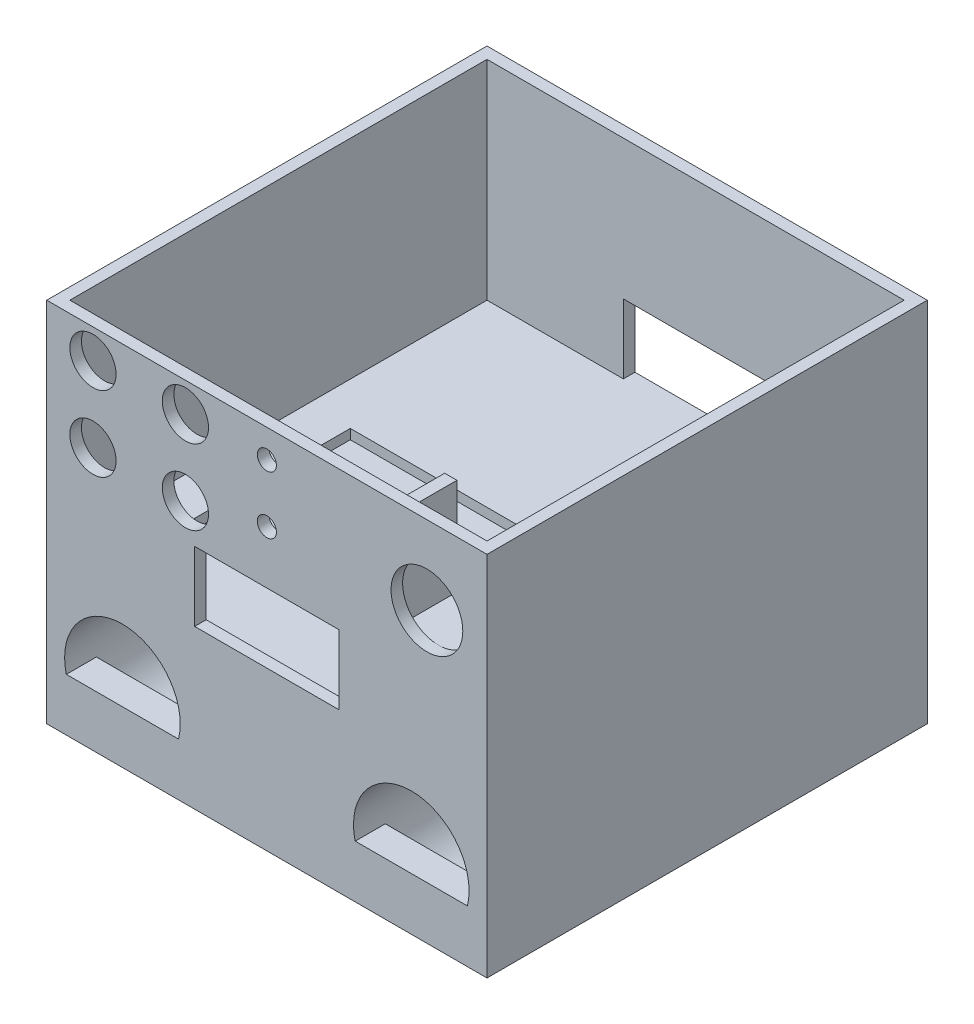
from build123d import *

# Parameters (mm, degrees)
SKETCH1_W           = 76.2
SKETCH1_H           = 76.2
BOSS_EXTRUDE1_DEPTH = 38.1
SHELL1_T            = -2
SKETCH2_W           = 25
SKETCH2_H           = 12
CUT_EXTRUDE1_DEPTH  = 115.3
CUT_EXTRUDE2_REACH  = 116.3
SKETCH3_R           = 4
CUT_EXTRUDE3_REACH  = 116.3
SKETCH4_R           = 6.2103
CUT_EXTRUDE4_REACH  = 116.3
SKETCH6_R           = 1.65
SKETCH1_2_W         = 76.2
SKETCH1_2_H         = 76.2
BOSS_EXTRUDE2_DEPTH = 25.4
SKETCH11_R          = 10
CUT_EXTRUDE6_DEPTH  = 71
CUT_EXTRUDE8_REACH  = 112.901
SKETCH16_W          = 51.308
SKETCH16_H          = 41.148
CUT_EXTRUDE9_DEPTH  = 1.7
BOSS_EXTRUDE3_DEPTH = 9.6774


with BuildPart() as part:
    # Sketch1 → Boss-Extrude1 (new body)
    with BuildSketch(Plane(origin=(0, 0, 0), x_dir=(1, 0, 0), z_dir=(0, 1, 0))):
        with Locations((38.1, 38.1)):
            Rectangle(SKETCH1_W, SKETCH1_H)
    extrude(amount=BOSS_EXTRUDE1_DEPTH)

    # Shell1
    shell1_openings = [part.faces().sort_by_distance(p)[0] for p in [
        (38.1, 38.1, -38.1),
    ]]
    offset(amount=SHELL1_T, openings=shell1_openings, kind=Kind.INTERSECTION)

    # Sketch2 → Cut-Extrude1 (cut, through all)
    with BuildSketch(Plane.XY):
        with Locations((38.1, 8)):
            Rectangle(SKETCH2_W, SKETCH2_H)
    extrude(amount=-CUT_EXTRUDE1_DEPTH, mode=Mode.SUBTRACT)

    # Sketch3 → Cut-Extrude2 (cut, up to next)
    with BuildSketch(Plane.XY, mode=Mode.PRIVATE) as cut_extrude2_sk1:
        with Locations((24, 20)):
            Circle(SKETCH3_R)
    cut_extrude2_tool1 = extrude(cut_extrude2_sk1.sketch, amount=-CUT_EXTRUDE2_REACH, mode=Mode.PRIVATE) & part.part
    # Sketch3 → Cut-Extrude2 (cut, up to next)
    with BuildSketch(Plane.XY, mode=Mode.PRIVATE) as cut_extrude2_sk2:
        with Locations((8, 20)):
            Circle(SKETCH3_R)
    cut_extrude2_tool2 = extrude(cut_extrude2_sk2.sketch, amount=-CUT_EXTRUDE2_REACH, mode=Mode.PRIVATE) & part.part
    # Sketch3 → Cut-Extrude2 (cut, up to next)
    with BuildSketch(Plane.XY, mode=Mode.PRIVATE) as cut_extrude2_sk3:
        with Locations((24, 33)):
            Circle(SKETCH3_R)
    cut_extrude2_tool3 = extrude(cut_extrude2_sk3.sketch, amount=-CUT_EXTRUDE2_REACH, mode=Mode.PRIVATE) & part.part
    # Sketch3 → Cut-Extrude2 (cut, up to next)
    with BuildSketch(Plane.XY, mode=Mode.PRIVATE) as cut_extrude2_sk4:
        with Locations((8, 33)):
            Circle(SKETCH3_R)
    cut_extrude2_tool4 = extrude(cut_extrude2_sk4.sketch, amount=-CUT_EXTRUDE2_REACH, mode=Mode.PRIVATE) & part.part
    add(cut_extrude2_tool1.solids().sort_by_distance((24, 20, 0))[0], mode=Mode.SUBTRACT)
    add(cut_extrude2_tool2.solids().sort_by_distance((8, 20, 0))[0], mode=Mode.SUBTRACT)
    add(cut_extrude2_tool3.solids().sort_by_distance((24, 33, 0))[0], mode=Mode.SUBTRACT)
    add(cut_extrude2_tool4.solids().sort_by_distance((8, 33, 0))[0], mode=Mode.SUBTRACT)

    # Sketch4 → Cut-Extrude3 (cut, up to next)
    with BuildSketch(Plane.XY, mode=Mode.PRIVATE) as cut_extrude3_sk1:
        with Locations((65.8, 24.5)):
            Circle(SKETCH4_R)
    cut_extrude3_tool1 = extrude(cut_extrude3_sk1.sketch, amount=-CUT_EXTRUDE3_REACH, mode=Mode.PRIVATE) & part.part
    add(cut_extrude3_tool1.solids().sort_by_distance((65.8, 24.5, 0))[0], mode=Mode.SUBTRACT)

    # Sketch6 → Cut-Extrude4 (cut, up to next)
    with BuildSketch(Plane.XY, mode=Mode.PRIVATE) as cut_extrude4_sk1:
        with Locations((38.1, 23.2)):
            Circle(SKETCH6_R)
    cut_extrude4_tool1 = extrude(cut_extrude4_sk1.sketch, amount=-CUT_EXTRUDE4_REACH, mode=Mode.PRIVATE) & part.part
    # Sketch6 → Cut-Extrude4 (cut, up to next)
    with BuildSketch(Plane.XY, mode=Mode.PRIVATE) as cut_extrude4_sk2:
        with Locations((38.1, 33.2)):
            Circle(SKETCH6_R)
    cut_extrude4_tool2 = extrude(cut_extrude4_sk2.sketch, amount=-CUT_EXTRUDE4_REACH, mode=Mode.PRIVATE) & part.part
    add(cut_extrude4_tool1.solids().sort_by_distance((38.1, 23.2, 0))[0], mode=Mode.SUBTRACT)
    add(cut_extrude4_tool2.solids().sort_by_distance((38.1, 33.2, 0))[0], mode=Mode.SUBTRACT)

    # Sketch1_2 → Boss-Extrude2 (add)
    with BuildSketch(Plane(origin=(0, 0, 0), x_dir=(1, 0, 0), z_dir=(0, 1, 0))):
        with Locations((38.1, 38.1)):
            Rectangle(SKETCH1_2_W, SKETCH1_2_H)
    extrude(amount=-BOSS_EXTRUDE2_DEPTH)

    # Sketch11 → Cut-Extrude6 (cut)
    with BuildSketch(Plane(origin=(0, 0, -76.2), x_dir=(-1, 0, 0), z_dir=(0, 0, -1))):
        with Locations((-63.1, -13.9)):
            Circle(SKETCH11_R)
        with Locations((-13.1, -13.9)):
            Circle(SKETCH11_R)
    extrude(amount=-CUT_EXTRUDE6_DEPTH, mode=Mode.SUBTRACT)

    # Sketch15 → Cut-Extrude8 (cut, up to next)
    with BuildSketch(Plane(origin=(0, 0, -5.2), x_dir=(-1, 0, 0), z_dir=(0, 0, -1)), mode=Mode.PRIVATE) as cut_extrude8_sk1:
        with BuildLine():
            Line((-72.809962586, -16.290946797), (-53.390037414, -16.290946797))
            ThreePointArc((-53.390037414, -16.290946797), (-63.1, -3.9), (-72.809962586, -16.290946797))
        make_face()
    cut_extrude8_tool1 = extrude(cut_extrude8_sk1.sketch, amount=-CUT_EXTRUDE8_REACH, mode=Mode.PRIVATE) & part.part
    # Sketch15 → Cut-Extrude8 (cut, up to next)
    with BuildSketch(Plane(origin=(0, 0, -5.2), x_dir=(-1, 0, 0), z_dir=(0, 0, -1)), mode=Mode.PRIVATE) as cut_extrude8_sk2:
        with BuildLine():
            Line((-22.809962586, -16.290946797), (-3.390037414, -16.290946797))
            ThreePointArc((-3.390037414, -16.290946797), (-13.1, -3.9), (-22.809962586, -16.290946797))
        make_face()
    cut_extrude8_tool2 = extrude(cut_extrude8_sk2.sketch, amount=-CUT_EXTRUDE8_REACH, mode=Mode.PRIVATE) & part.part
    add(cut_extrude8_tool1.solids().sort_by_distance((63.1, -10.914633, -5.2))[0], mode=Mode.SUBTRACT)
    add(cut_extrude8_tool2.solids().sort_by_distance((13.1, -10.914633, -5.2))[0], mode=Mode.SUBTRACT)

    # Sketch16 → Cut-Extrude9 (cut)
    with BuildSketch(Plane(origin=(0, 2, 0), x_dir=(1, 0, 0), z_dir=(0, 1, 0))):
        with Locations((35.046, 22.574)):
            Rectangle(SKETCH16_W, SKETCH16_H)
    extrude(amount=-CUT_EXTRUDE9_DEPTH, mode=Mode.SUBTRACT)

    # Sketch19 → Boss-Extrude3 (add)
    with BuildSketch(Plane(origin=(0, 0, -2), x_dir=(-1, 0, 0), z_dir=(0, 0, -1))):
        Polygon((-59.323, 34.9267), (-59.323, 18.1867), (-72.277, 18.1867), (-72.277, 34.9267), (-74.2, 34.9267), (-74.2, 15.742753149), (-57.2, 15.742753149), (-57.2, 34.9267), align=None)
    extrude(amount=BOSS_EXTRUDE3_DEPTH)


solid = part.part
